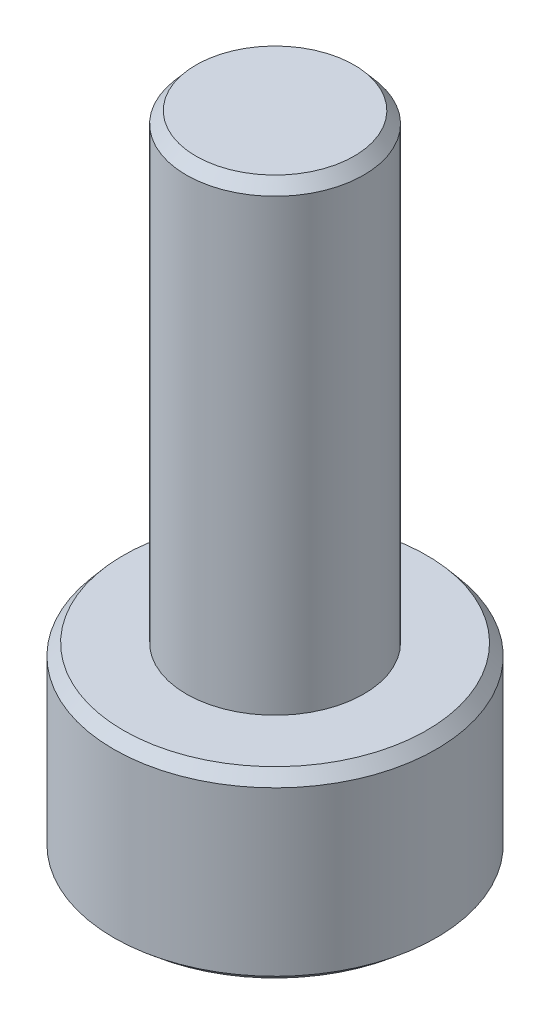
from build123d import *

# Parameters (mm, degrees)
SKETCH1_R             = 3.5
BOSS_EXTRUDE1_DEPTH   = 4
SKETCH2_R             = 1.925
BOSS_EXTRUDE2_DEPTH   = 10
CUT_EXTRUDE1_DEPTH    = 2
CHAMFER1_SIZE         = 0.25
CHAMFER1_SIZE2        = 0.209774908
CHAMFER1_PART_2_SIZE  = 0.25
CHAMFER1_PART_2_SIZE2 = 0.209774908
CHAMFER1_PART_3_SIZE  = 0.25
CHAMFER1_PART_3_SIZE2 = 0.209774908


with BuildPart() as part:
    # Sketch1 → Boss-Extrude1 (new body)
    with BuildSketch(Plane(origin=(0, 0, 0), x_dir=(1, 0, 0), z_dir=(0, 1, 0))):
        Circle(SKETCH1_R)
    extrude(amount=BOSS_EXTRUDE1_DEPTH)

    # Sketch2 → Boss-Extrude2 (add)
    with BuildSketch(Plane(origin=(0, 4, 0), x_dir=(1, 0, 0), z_dir=(0, 1, 0))):
        Circle(SKETCH2_R)
    extrude(amount=BOSS_EXTRUDE2_DEPTH)

    # Sketch3 → Cut-Extrude1 (cut)
    with BuildSketch(Plane.XZ):
        Polygon((0, 2.37190351), (-2.054128695, 1.185951755), (-2.054128695, -1.185951755), (0, -2.37190351), (2.054128695, -1.185951755), (2.054128695, 1.185951755), align=None)
    extrude(amount=-CUT_EXTRUDE1_DEPTH, mode=Mode.SUBTRACT)

    # Chamfer1
    chamfer1_edges = [part.edges().sort_by_distance(p)[0] for p in [
        (1.027064348, 0, 1.778927633),
        (-1.027064348, 0, 1.778927633),
        (-2.054128695, 0, 0),
        (-1.027064348, 0, -1.778927633),
        (1.027064348, 0, -1.778927633),
        (2.054128695, 0, 0),
        (-3.5, 0, 0),
    ]]
    chamfer1_side = [part.faces().sort_by_distance(p)[0] for p in [
        (-3.401005051, 0, 0),
    ]]
    chamfer(chamfer1_edges, length=CHAMFER1_SIZE, length2=CHAMFER1_SIZE2, reference=chamfer1_side[0])

    # Chamfer1 part 2
    chamfer1_part_2_edges = [part.edges().sort_by_distance(p)[0] for p in [
        (-3.5, 4, 0),
    ]]
    chamfer1_part_2_side = [part.faces().sort_by_distance(p)[0] for p in [
        (-3.5, 2, 0),
    ]]
    chamfer(chamfer1_part_2_edges, length=CHAMFER1_PART_2_SIZE, length2=CHAMFER1_PART_2_SIZE2, reference=chamfer1_part_2_side[0])

    # Chamfer1 part 3
    chamfer1_part_3_edges = [part.edges().sort_by_distance(p)[0] for p in [
        (-1.925, 14, 0),
    ]]
    chamfer1_part_3_side = [part.faces().sort_by_distance(p)[0] for p in [
        (-1.925, 9, 0),
    ]]
    chamfer(chamfer1_part_3_edges, length=CHAMFER1_PART_3_SIZE, length2=CHAMFER1_PART_3_SIZE2, reference=chamfer1_part_3_side[0])


solid = part.part
